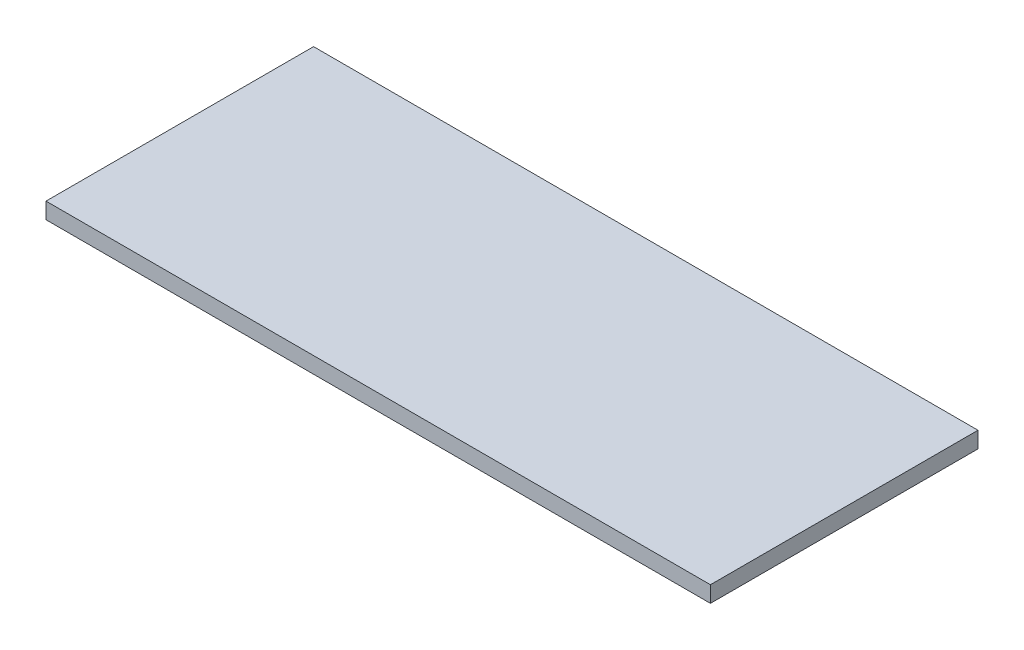
from build123d import *

# Parameters (mm, degrees)
SKETCH_1_W      = 740
SKETCH_1_H      = 298
EXTRUDE_1_DEPTH = 18


with BuildPart() as part:
    # Эскиз1 → Бобышка-Вытянуть1 (new body)
    with BuildSketch(Plane(origin=(0, 0, 0), x_dir=(1, 0, 0), z_dir=(0, 1, 0))):
        Rectangle(SKETCH_1_W, SKETCH_1_H)
    extrude(amount=EXTRUDE_1_DEPTH)


solid = part.part
